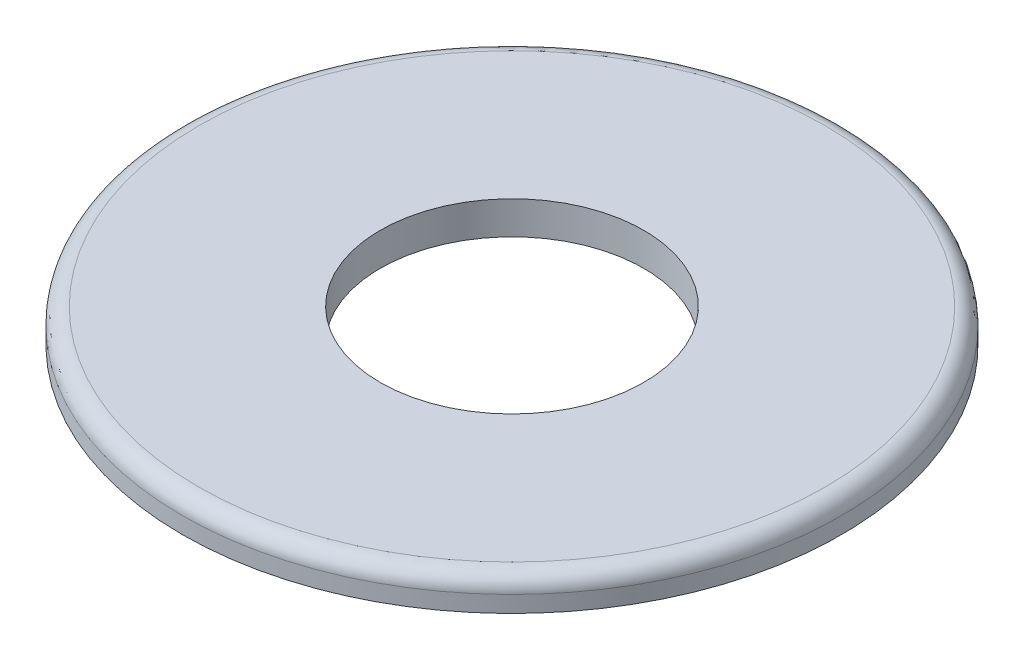
from build123d import *

# Parameters (mm, degrees)
SKETCH1_R           = 10
SKETCH1_R_2         = 4
BOSS_EXTRUDE1_DEPTH = 1
FILLET1_R           = 0.5


with BuildPart() as part:
    # Sketch1 → Boss-Extrude1 (new body)
    with BuildSketch(Plane(origin=(0, 0, 0), x_dir=(1, 0, 0), z_dir=(0, 1, 0))):
        with Locations(Location((0, 0, 0), (0, 0, 270))):  # turned: the seam where the file's is
            Circle(SKETCH1_R)
        with Locations(Location((0, 0, 0), (0, 0, 270))):  # turned: the seam where the file's is
            Circle(SKETCH1_R_2, mode=Mode.SUBTRACT)
    extrude(amount=BOSS_EXTRUDE1_DEPTH)

    # Fillet1
    fillet1_edges = [part.edges().sort_by_distance(p)[0] for p in [
        (0, 1, -10),
    ]]
    fillet(fillet1_edges, radius=FILLET1_R)


solid = part.part
